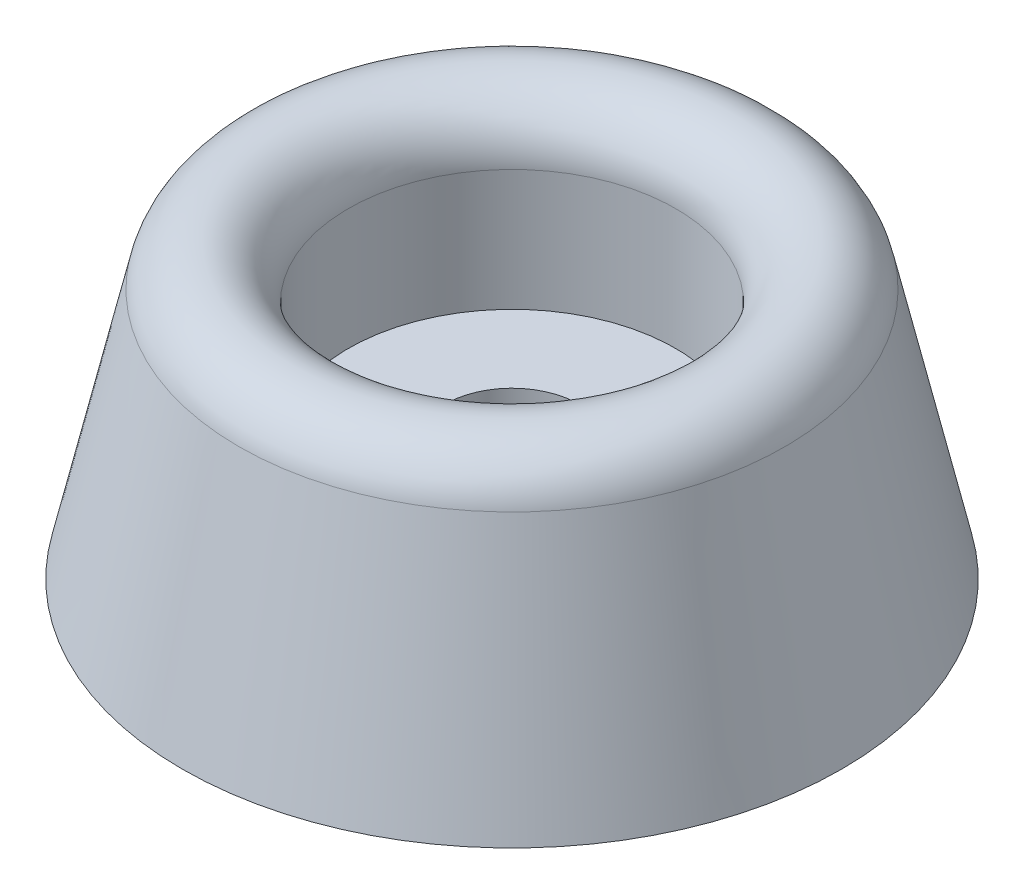
from build123d import *


with BuildPart() as part:
    # Croquis1 → Revolución1 (revolve)
    with BuildSketch(Plane(origin=(0, 0, 0), x_dir=(-1, 0, 0), z_dir=(0, 0, -1))):
        with BuildLine():
            Line((-1.6, -3e-09), (-1.6, 2.8))
            Line((-1.6, 2.8), (-3.9, 2.8))
            Line((-3.9, 2.8), (-3.9, 5.683813699))
            ThreePointArc((-3.9, 5.683813699), (-5.07022676, 6.991881813), (-6.500000001, 5.973932235))
            Line((-6.500000001, 5.973932235), (-7.849999989, -3e-09))
            Line((-7.849999989, -3e-09), (-1.6, -3e-09))
        make_face()
    revolve(axis=Axis((0, -3e-09, 0), (0, 1, 0)))


solid = part.part
